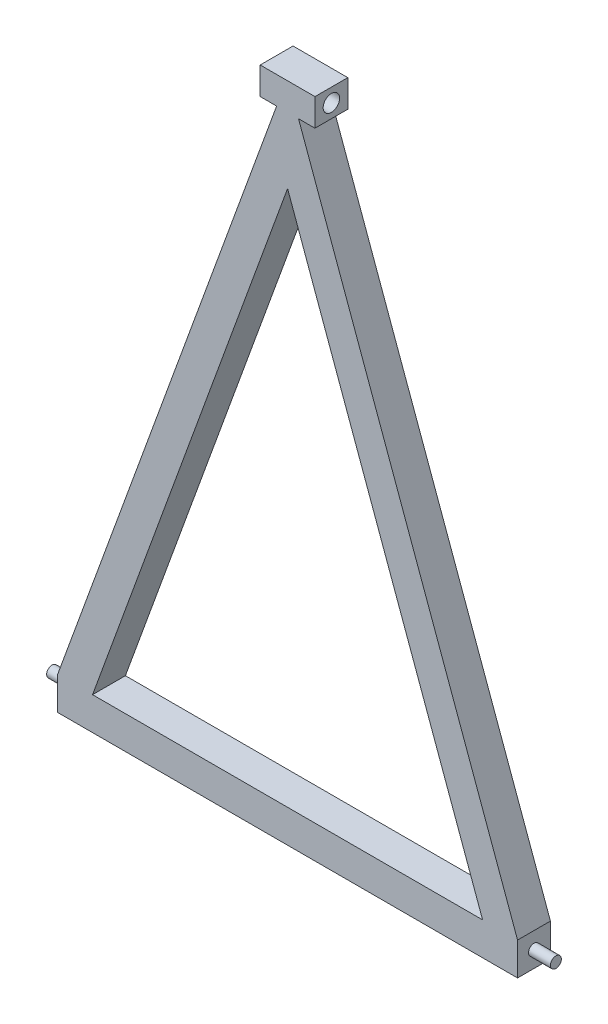
from build123d import *

# Parameters (mm, degrees)
BOSS_EXTRUDE1_DEPTH = 76.2
SKETCH2_R           = 19.05
CUT_EXTRUDE1_DEPTH  = 140.97
SKETCH3_R           = 12.7
BOSS_EXTRUDE2_DEPTH = 50.8
SKETCH4_R           = 12.7
BOSS_EXTRUDE3_DEPTH = 50.8


with BuildPart() as part:
    # Sketch1 → Boss-Extrude1 (new body)
    with BuildSketch(Plane.XY):
        Polygon((0, 0), (533.4, 0), (533.4, 76.2), (25.4, 1471.918529083), (63.5, 1471.918529083), (63.5, 1535.418529083), (-63.5, 1535.418529083), (-63.5, 1471.918529083), (-25.4, 1471.918529083), (-533.4, 76.2), (-533.4, 0), align=None)
        Polygon((-452.309653737, 76.2), (452.309653737, 76.2), (0, 1318.910560245), align=None, mode=Mode.SUBTRACT)
    extrude(amount=BOSS_EXTRUDE1_DEPTH)

    # Sketch2 → Cut-Extrude1 (cut)
    with BuildSketch(Plane(origin=(63.5, 0, 0), x_dir=(0, 0, -1), z_dir=(1, 0, 0))):
        with Locations((-38.1, 1503.668529083)):
            Circle(SKETCH2_R)
    extrude(amount=-CUT_EXTRUDE1_DEPTH, mode=Mode.SUBTRACT)

    # Sketch3 → Boss-Extrude2 (add)
    with BuildSketch(Plane.ZY.offset(533.4)):
        with Locations((38.1, 38.1)):
            Circle(SKETCH3_R)
    extrude(amount=BOSS_EXTRUDE2_DEPTH)

    # Sketch4 → Boss-Extrude3 (add)
    with BuildSketch(Plane(origin=(533.4, 0, 0), x_dir=(0, 0, -1), z_dir=(1, 0, 0))):
        with Locations((-38.1, 38.1)):
            Circle(SKETCH4_R)
    extrude(amount=BOSS_EXTRUDE3_DEPTH)


solid = part.part
